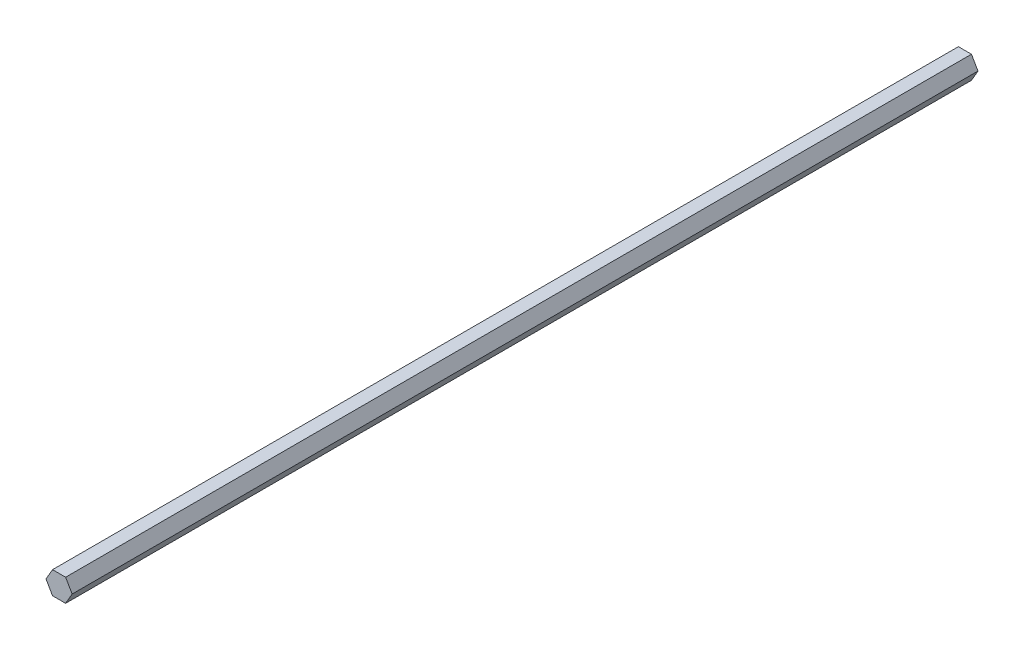
from build123d import *

# Parameters (mm, degrees)
BOSS_EXTRUDE1_DEPTH = 508


with BuildPart() as part:
    # Sketch1 → Boss-Extrude1 (new body)
    with BuildSketch(Plane.XY):
        Polygon((7.332348419, 0), (3.666174209, 6.35), (-3.666174209, 6.35), (-7.332348419, 0), (-3.666174209, -6.35), (3.666174209, -6.35), align=None)
    extrude(amount=BOSS_EXTRUDE1_DEPTH)


solid = part.part
